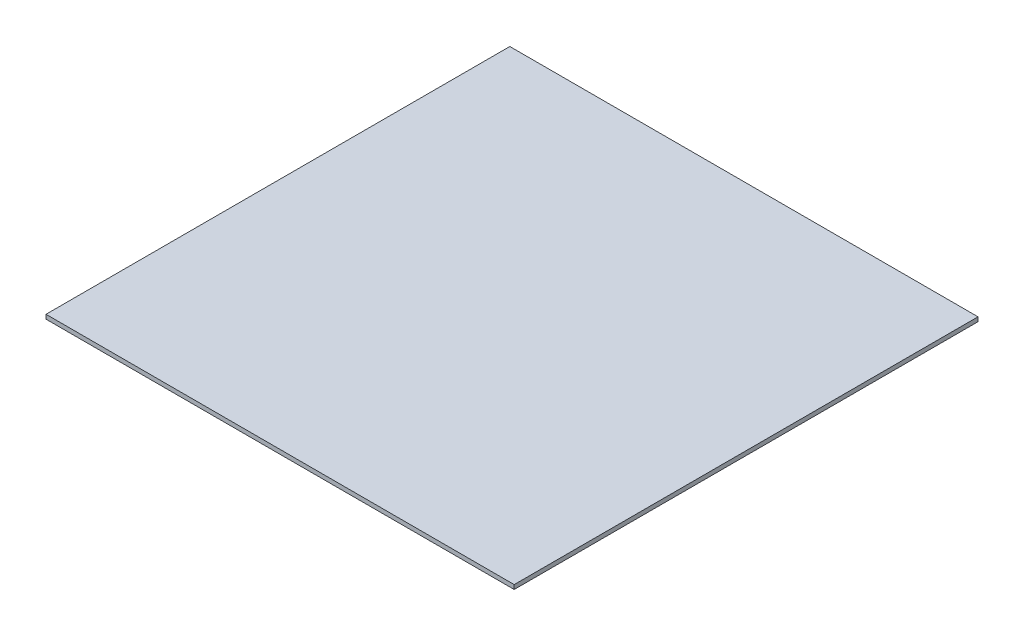
from build123d import *

# Parameters (mm, degrees)
SKETCH1_W           = 609.6
SKETCH1_H           = 603.885
BOSS_EXTRUDE1_DEPTH = 5.55625


with BuildPart() as part:
    # Sketch1 → Boss-Extrude1 (new body)
    with BuildSketch(Plane(origin=(0, 0, 0), x_dir=(1, 0, 0), z_dir=(0, 1, 0))):
        Rectangle(SKETCH1_W, SKETCH1_H)
    extrude(amount=BOSS_EXTRUDE1_DEPTH)


solid = part.part
